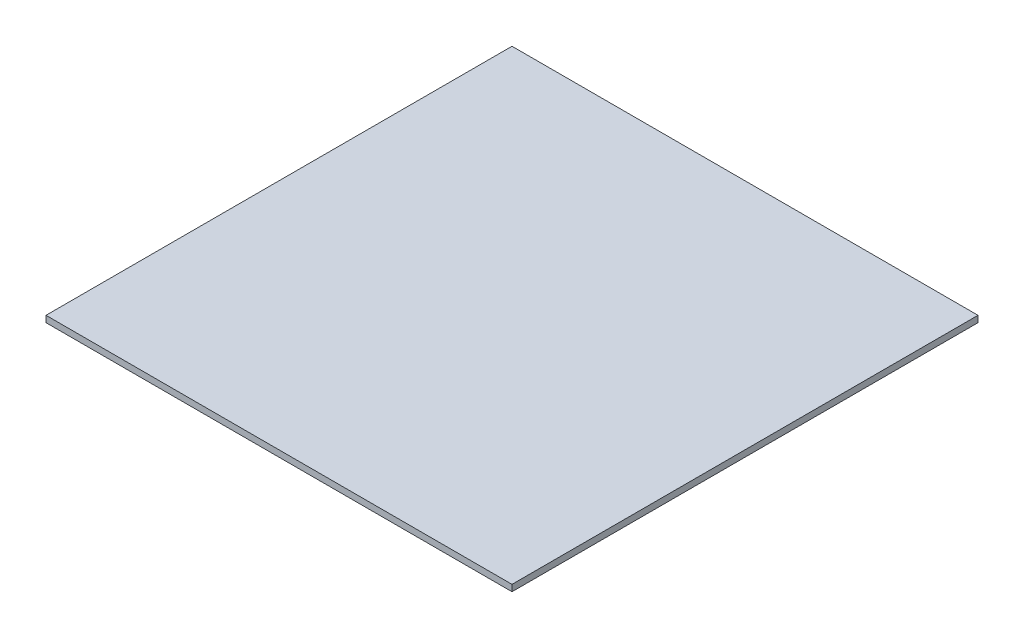
from build123d import *

# Parameters (mm, degrees)
SKETCH1_W           = 406.4
SKETCH1_H           = 406.4
BOSS_EXTRUDE1_DEPTH = 5.6


with BuildPart() as part:
    # Sketch1 → Boss-Extrude1 (new body)
    with BuildSketch(Plane(origin=(0, 0, 0), x_dir=(1, 0, 0), z_dir=(0, 1, 0))):
        Rectangle(SKETCH1_W, SKETCH1_H)
    extrude(amount=BOSS_EXTRUDE1_DEPTH)


solid = part.part
